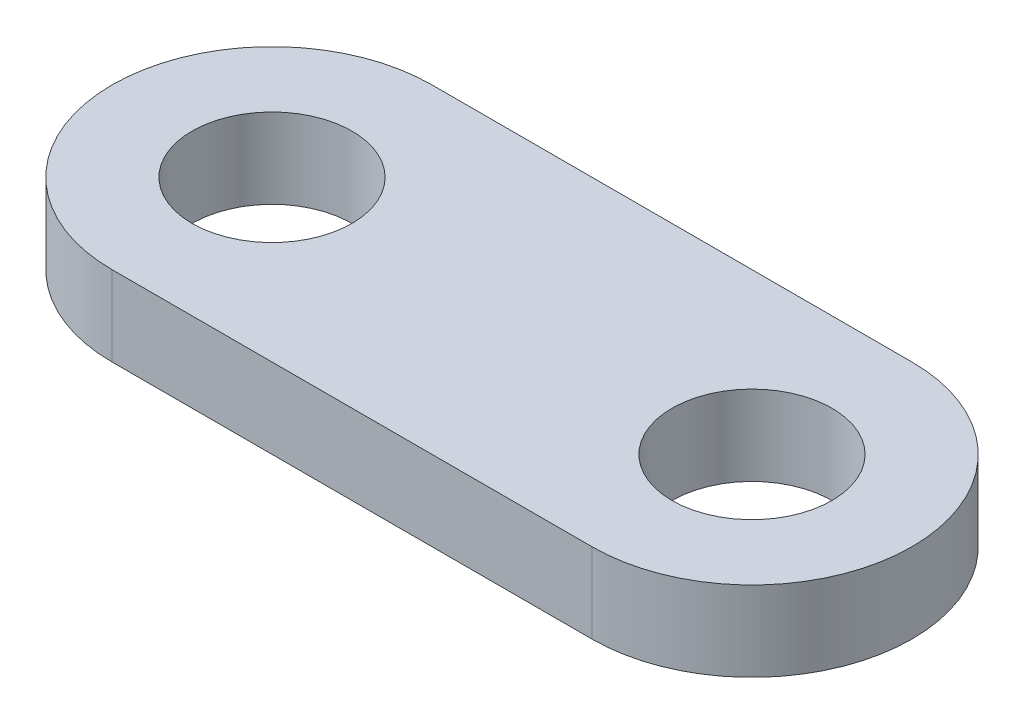
from build123d import *

# Parameters (mm, degrees)
SKETCH2_R           = 5
BOSS_EXTRUDE1_DEPTH = 5


with BuildPart() as part:
    # Sketch2 → Boss-Extrude1 (new body)
    with BuildSketch(Plane(origin=(0, 0, 0), x_dir=(1, 0, 0), z_dir=(0, 1, 0))):
        with BuildLine():
            Line((0, 10), (30, 10))
            ThreePointArc((30, 10), (40, 0), (30, -10))
            Line((30, -10), (0, -10))
            ThreePointArc((0, -10), (-10, 0), (0, 10))
        make_face()
        Circle(SKETCH2_R, mode=Mode.SUBTRACT)
        with Locations((30, 0)):
            Circle(SKETCH2_R, mode=Mode.SUBTRACT)
    extrude(amount=BOSS_EXTRUDE1_DEPTH)


solid = part.part
